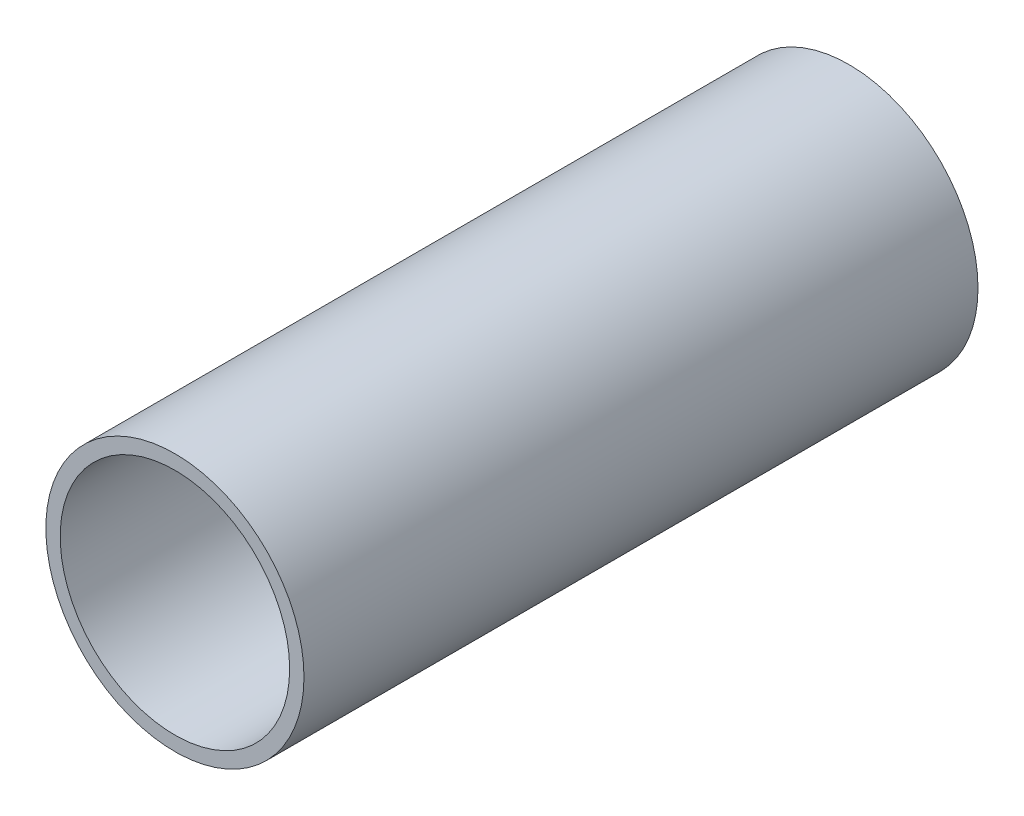
from build123d import *

# Parameters (mm, degrees)
SKETCH1_R           = 57.15
SKETCH1_R_2         = 50.8
BOSS_EXTRUDE1_DEPTH = 149.225


with BuildPart() as part:
    # Sketch1 → Boss-Extrude1 (new body, symmetric)
    with BuildSketch(Plane.XY):
        Circle(SKETCH1_R)
        Circle(SKETCH1_R_2, mode=Mode.SUBTRACT)
    extrude(amount=BOSS_EXTRUDE1_DEPTH, both=True)


solid = part.part
